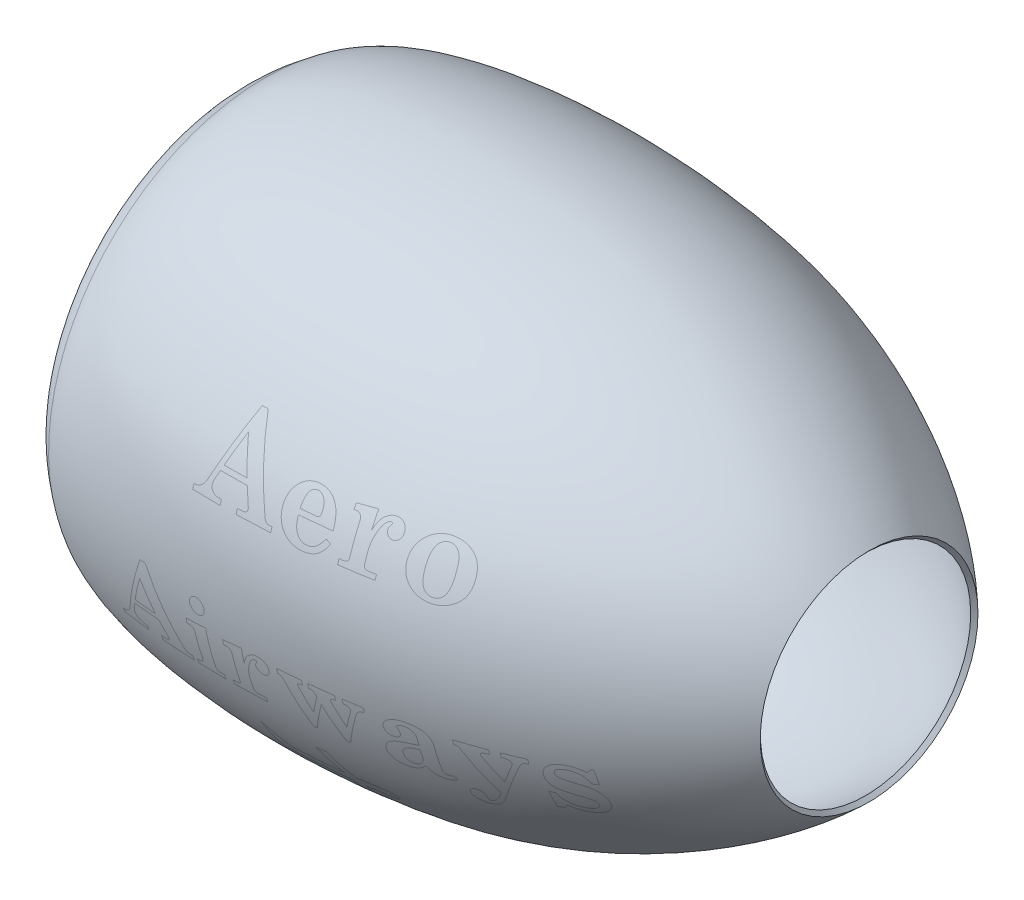
from build123d import *

# Parameters (mm, degrees)
THICKEN1_T1 = 5


with BuildPart() as body_1:
    # Surface-Revolve1: a surface, the sketch's curves turned about an axis
    with BuildLine(Plane.XY, mode=Mode.PRIVATE) as surface_revolve1_1_path:
        Line((58.038146133, 190), (33.038146133, 190))
        Line((33.038146133, 190), (25, 166))
        Line((25, 166), (0, 166))
        add(Edge.make_bspline(
            [(0, 166), (-6.873872274, 166), (-20.256903083, 176.553880741), (-19.680490958, 190.479362397), (-10.506905999, 197.382493162), (0, 205.478108127)],
            knots=[0, 0, 0, 0, 0.438428561, 0.538428561, 1, 1, 1, 1], degree=3))
        add(Edge.make_bspline(
            [(0, 205.478108127), (34.370478775, 231.960705608), (189.028774324, 249.684921051), (436.056860326, 207.105462323), (533.885540134, 146.150551093), (580, 102)],
            knots=[0, 0, 0, 0, 0.513369486, 0.613369486, 1, 1, 1, 1], degree=3))
    surface_revolve1_1 = Shell.revolve(surface_revolve1_1_path.wire(), 360, Axis((0, 0, 0), (1, 0, 0)))
    add(Solid.thicken(surface_revolve1_1, THICKEN1_T1))


solid = body_1.part
